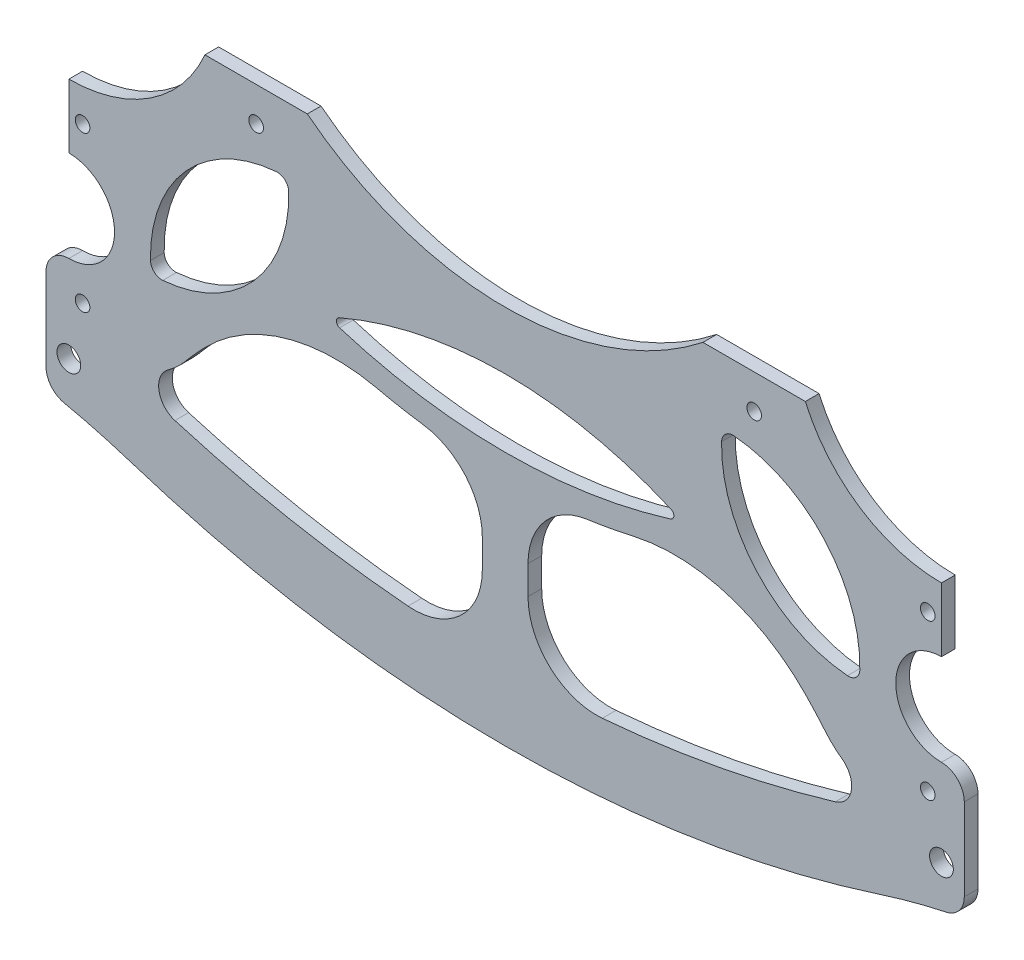
from build123d import *

# Parameters (mm, degrees)
EXTRUDE_1_DEPTH     = 3
EXTRUDE_1_2_DEPTH   = 3
FILLET_1_R          = 40
CUT_EXTRUDE_1_REACH = 5
FILLET_2_R          = 20
CUT_EXTRUDE_2_REACH = 5
SKETCH_4_R          = 1.6
CUT_EXTRUDE_3_REACH = 5
SKETCH_5_R          = 1.6
FILLET_3_R          = 1
SKETCH_6_R          = 1.6
SKETCH_6_R_2        = 2.6
EXTRUDE_2_DEPTH     = 3
FILLET_4_R          = 30
FILLET_5_R          = 2.5
EXTRUDE_2_2_DEPTH   = 3
SKETCH_8_R          = 2.6
CUT_EXTRUDE_4_DEPTH = 3
SKETCH_9_W          = 10
SKETCH_9_H          = 47.117031465
EXTRUDE_3_DEPTH     = 3
FILLET_6_R          = 15
FILLET_7_R          = 15
FILLET_8_R          = 5
FILLET_9_R          = 145


with BuildPart() as part:
    # 草图1 → Extrude 1 (new body)
    with BuildSketch(Plane.XY):
        with BuildLine():
            ThreePointArc((-43.301270189, 33.75), (0, 18.75), (43.301270189, 33.75))
            Line((43.301270189, 33.75), (65.713257983, 33.75))
            ThreePointArc((65.713257983, 33.75), (77.699016881, 19.558549138), (95.5, 14.25))
            Line((95.5, 14.25), (95.5, 0.25))
            ThreePointArc((95.5, 0.25), (85.5, -9.75), (95.5, -19.75))
            Line((95.5, -19.75), (95.5, -33.75))
            Line((95.5, -33.75), (75.5, -33.75))
            ThreePointArc((75.5, -33.75), (0, 6.139830406), (-75.5, -33.75))
            Line((-75.5, -33.75), (-95.5, -33.75))
            Line((-95.5, -33.75), (-95.5, -19.75))
            ThreePointArc((-95.5, -19.75), (-85.5, -9.75), (-95.5, 0.25))
            Line((-95.5, 0.25), (-95.5, 14.25))
            ThreePointArc((-95.5, 14.25), (-77.699016881, 19.558549138), (-65.713257983, 33.75))
            Line((-65.713257983, 33.75), (-43.301270189, 33.75))
        make_face()
    extrude(amount=EXTRUDE_1_DEPTH)

    # 草图2 → Extrude 1 2 (add)
    with BuildSketch(Plane.XY.offset(3)):
        with BuildLine():
            ThreePointArc((-73.077723915, 9.270833333), (1.020159466, -13.745918659), (74.740241536, 10.453599796))
            Line((74.740241536, 10.453599796), (71.809251672, 14.50443902))
            ThreePointArc((71.809251672, 14.50443902), (0.980153213, -8.746078711), (-70.211930821, 13.368055556))
            Line((-70.211930821, 13.368055556), (-73.077723915, 9.270833333))
        make_face()
    extrude(amount=-EXTRUDE_1_2_DEPTH)

    # 圆角1
    fillet_1_edges = [part.edges().sort_by_distance(p)[0] for p in [
        (44.828445276, -5.609375393, 1.5),
        (-44.828445276, -5.609375393, 1.5),
    ]]
    fillet(fillet_1_edges, radius=FILLET_1_R)

    # 草图3 → 切除-拉伸1 (cut, up to next)
    with BuildSketch(Plane.XY.offset(3), mode=Mode.PRIVATE) as cut_extrude_1_sk1:
        with BuildLine():
            ThreePointArc((-77.464525403, -13.719576202), (-55.070861932, -3.793658796), (-47.54009497, 19.514870736))
            ThreePointArc((-47.54009497, 19.514870736), (-69.933758441, 9.588953331), (-77.464525403, -13.719576202))
        make_face()
    cut_extrude_1_tool1 = extrude(cut_extrude_1_sk1.sketch, amount=-CUT_EXTRUDE_1_REACH, mode=Mode.PRIVATE) & part.part
    add(cut_extrude_1_tool1.solids().sort_by_distance((-62.50231, 2.897647, 3))[0], mode=Mode.SUBTRACT)
    # 草图3 → 切除-拉伸1 (cut, up to next)
    with BuildSketch(Plane.XY.offset(3), mode=Mode.PRIVATE) as cut_extrude_1_sk2:
        with BuildLine():
            ThreePointArc((77.464525403, -13.719576202), (69.933758441, 9.588953331), (47.54009497, 19.514870736))
            ThreePointArc((47.54009497, 19.514870736), (55.070861932, -3.793658796), (77.464525403, -13.719576202))
        make_face()
    cut_extrude_1_tool2 = extrude(cut_extrude_1_sk2.sketch, amount=-CUT_EXTRUDE_1_REACH, mode=Mode.PRIVATE) & part.part
    add(cut_extrude_1_tool2.solids().sort_by_distance((62.50231, 2.897647, 3))[0], mode=Mode.SUBTRACT)

    # 圆角2
    fillet_2_edges = [part.edges().sort_by_distance(p)[0] for p in [
        (75.5, -33.75, 1.5),
        (-75.5, -33.75, 1.5),
    ]]
    fillet(fillet_2_edges, radius=FILLET_2_R)

    # 草图4 → 切除-拉伸2 (cut, up to next)
    with BuildSketch(Plane.XY.offset(3), mode=Mode.PRIVATE) as cut_extrude_2_sk1:
        with Locations((-92.5, -26.75)):
            Circle(SKETCH_4_R)
    cut_extrude_2_tool1 = extrude(cut_extrude_2_sk1.sketch, amount=-CUT_EXTRUDE_2_REACH, mode=Mode.PRIVATE) & part.part
    add(cut_extrude_2_tool1.solids().sort_by_distance((-92.5, -26.75, 3))[0], mode=Mode.SUBTRACT)
    # 草图4 → 切除-拉伸2 (cut, up to next)
    with BuildSketch(Plane.XY.offset(3), mode=Mode.PRIVATE) as cut_extrude_2_sk2:
        with Locations((-92.5, 7.25)):
            Circle(SKETCH_4_R)
    cut_extrude_2_tool2 = extrude(cut_extrude_2_sk2.sketch, amount=-CUT_EXTRUDE_2_REACH, mode=Mode.PRIVATE) & part.part
    add(cut_extrude_2_tool2.solids().sort_by_distance((-92.5, 7.25, 3))[0], mode=Mode.SUBTRACT)
    # 草图4 → 切除-拉伸2 (cut, up to next)
    with BuildSketch(Plane.XY.offset(3), mode=Mode.PRIVATE) as cut_extrude_2_sk3:
        with Locations((92.5, 7.25)):
            Circle(SKETCH_4_R)
    cut_extrude_2_tool3 = extrude(cut_extrude_2_sk3.sketch, amount=-CUT_EXTRUDE_2_REACH, mode=Mode.PRIVATE) & part.part
    add(cut_extrude_2_tool3.solids().sort_by_distance((92.5, 7.25, 3))[0], mode=Mode.SUBTRACT)
    # 草图4 → 切除-拉伸2 (cut, up to next)
    with BuildSketch(Plane.XY.offset(3), mode=Mode.PRIVATE) as cut_extrude_2_sk4:
        with Locations((92.5, -26.75)):
            Circle(SKETCH_4_R)
    cut_extrude_2_tool4 = extrude(cut_extrude_2_sk4.sketch, amount=-CUT_EXTRUDE_2_REACH, mode=Mode.PRIVATE) & part.part
    add(cut_extrude_2_tool4.solids().sort_by_distance((92.5, -26.75, 3))[0], mode=Mode.SUBTRACT)

    # 草图5 → 切除-拉伸3 (cut, up to next)
    with BuildSketch(Plane.XY.offset(3), mode=Mode.PRIVATE) as cut_extrude_3_sk1:
        with Locations((-54.507264086, 26.25)):
            Circle(SKETCH_5_R)
    cut_extrude_3_tool1 = extrude(cut_extrude_3_sk1.sketch, amount=-CUT_EXTRUDE_3_REACH, mode=Mode.PRIVATE) & part.part
    add(cut_extrude_3_tool1.solids().sort_by_distance((-54.507264, 26.25, 3))[0], mode=Mode.SUBTRACT)
    # 草图5 → 切除-拉伸3 (cut, up to next)
    with BuildSketch(Plane.XY.offset(3), mode=Mode.PRIVATE) as cut_extrude_3_sk2:
        with Locations((54.507264086, 26.25)):
            Circle(SKETCH_5_R)
    cut_extrude_3_tool2 = extrude(cut_extrude_3_sk2.sketch, amount=-CUT_EXTRUDE_3_REACH, mode=Mode.PRIVATE) & part.part
    add(cut_extrude_3_tool2.solids().sort_by_distance((54.507264, 26.25, 3))[0], mode=Mode.SUBTRACT)

    # 圆角3
    fillet_3_edges = [part.edges().sort_by_distance(p)[0] for p in [
        (38.722757726, -2.468750785, 1.5),
        (-38.722757726, -2.468750785, 1.5),
    ]]
    fillet(fillet_3_edges, radius=FILLET_3_R)

    # 草图6 → Extrude 2 (add)
    with BuildSketch(Plane.XY.offset(3)):
        with BuildLine():
            Line((-90.5, -24.75), (-90.5, -42.75))
            ThreePointArc((-90.5, -42.75), (-95.5, -47.75), (-100.5, -42.75))
            Line((-100.5, -42.75), (-100.5, -24.75))
            ThreePointArc((-100.5, -24.75), (-95.5, -19.75), (-90.5, -24.75))
        make_face()
        with Locations((-92.5, -26.75)):
            Circle(SKETCH_6_R, mode=Mode.SUBTRACT)
        with Locations((-95.5, -38.75)):
            Circle(SKETCH_6_R_2, mode=Mode.SUBTRACT)
        with BuildLine():
            Line((90.5, -24.75), (90.5, -42.75))
            ThreePointArc((90.5, -42.75), (95.5, -47.75), (100.5, -42.75))
            Line((100.5, -42.75), (100.5, -24.75))
            ThreePointArc((100.5, -24.75), (95.5, -19.75), (90.5, -24.75))
        make_face()
        with Locations((92.5, -26.75)):
            Circle(SKETCH_6_R, mode=Mode.SUBTRACT)
        with Locations((95.5, -38.75)):
            Circle(SKETCH_6_R_2, mode=Mode.SUBTRACT)
    extrude(amount=-EXTRUDE_2_DEPTH)

    # 圆角4
    fillet_4_edges = [part.edges().sort_by_distance(p)[0] for p in [
        (90.5, -33.75, 1.5),
        (-90.5, -33.75, 1.5),
    ]]
    fillet(fillet_4_edges, radius=FILLET_4_R)

    # 圆角5
    fillet_5_edges = [part.edges().sort_by_distance(p)[0] for p in [
        (-77.464525403, -13.719576202, 1.5),
        (-47.54009497, 19.514870736, 1.5),
        (77.464525403, -13.719576202, 1.5),
        (47.54009497, 19.514870736, 1.5),
    ]]
    fillet(fillet_5_edges, radius=FILLET_5_R)

    # 草图7 → Extrude 2 2 (add)
    with BuildSketch(Plane(origin=(0, 0, 0), x_dir=(-1, 0, 0), z_dir=(0, 0, -1))):
        with BuildLine():
            ThreePointArc((-98.254807692, -45.725746166), (-1.428275693, -64.420319839), (95.592366359, -46.760778516))
            Line((95.592366359, -46.760778516), (90.23204675, -32.751246986))
            ThreePointArc((90.23204675, -32.751246986), (-1.348185467, -49.420533656), (-92.745192308, -31.774253834))
            Line((-92.745192308, -31.774253834), (-98.254807692, -45.725746166))
        make_face()
    extrude(amount=-EXTRUDE_2_2_DEPTH)

    # 草图8 → 切除-拉伸4 (cut)
    with BuildSketch(Plane(origin=(0, 0, 0), x_dir=(-1, 0, 0), z_dir=(0, 0, -1))):
        with Locations((-95.5, -38.75)):
            Circle(SKETCH_8_R)
        with Locations((95.5, -38.75)):
            Circle(SKETCH_8_R)
    extrude(amount=-CUT_EXTRUDE_4_DEPTH, mode=Mode.SUBTRACT)

    # 草图9 → 拉伸-薄壁3 (add)
    with BuildSketch(Plane(origin=(0, 0, 0), x_dir=(-1, 0, 0), z_dir=(0, 0, -1))):
        with Locations((0, -35.055916217)):
            Rectangle(SKETCH_9_W, SKETCH_9_H)
    extrude(amount=-EXTRUDE_3_DEPTH)

    # 圆角6
    fillet_6_edges = [part.edges().sort_by_distance(p)[0] for p in [
        (-5, -49.374623093, 1.5),
        (5, -49.374623093, 1.5),
    ]]
    fillet(fillet_6_edges, radius=FILLET_6_R)

    # 圆角7
    fillet_7_edges = [part.edges().sort_by_distance(p)[0] for p in [
        (5, -13.651923062, 1.5),
        (-5, -13.651923062, 1.5),
    ]]
    fillet(fillet_7_edges, radius=FILLET_7_R)

    # 圆角8
    fillet_8_edges = [part.edges().sort_by_distance(p)[0] for p in [
        (-82.894303889, -35.42944601, 1.5),
        (82.894303889, -35.42944601, 1.5),
    ]]
    fillet(fillet_8_edges, radius=FILLET_8_R)

    # 圆角9
    fillet_9_edges = [part.edges().sort_by_distance(p)[0] for p in [
        (93.782514434, -47.445768662, 1.5),
        (-93.782514434, -47.445768662, 1.5),
    ]]
    fillet(fillet_9_edges, radius=FILLET_9_R)


solid = part.part
